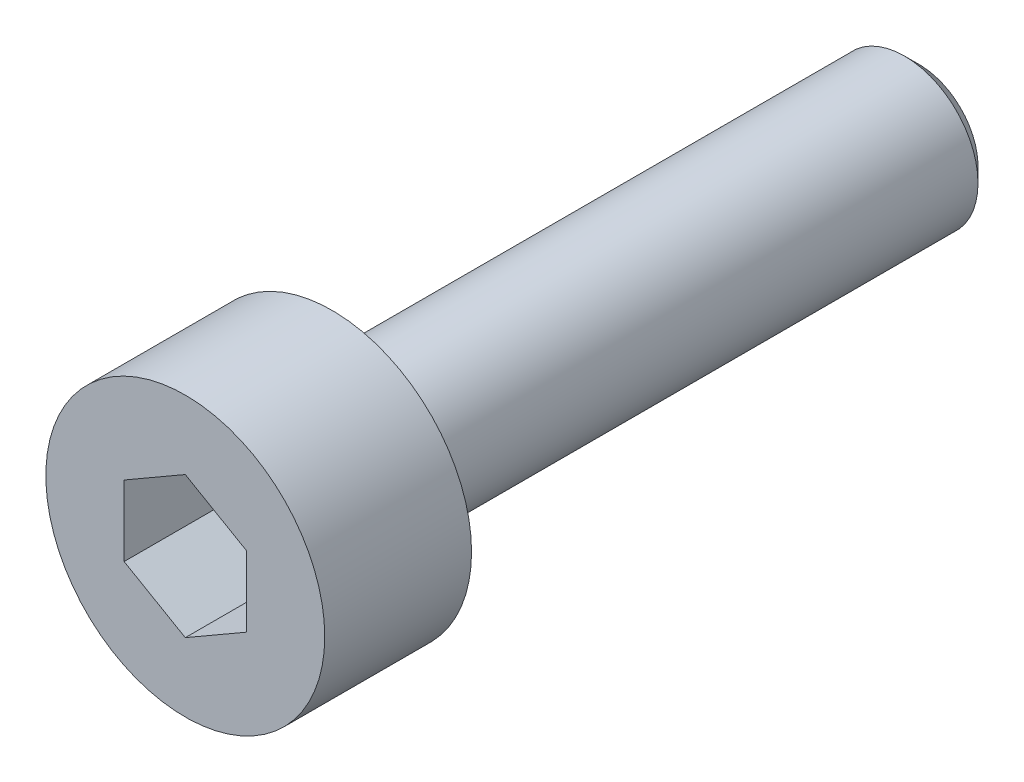
from build123d import *

# Parameters (mm, degrees)
SKETCH1_R           = 2.85
BOSS_EXTRUDE1_DEPTH = 3
SKETCH2_R           = 1.5
BOSS_EXTRUDE2_DEPTH = 12
CHAMFER1_SIZE       = 0.3
CUT_EXTRUDE1_DEPTH  = 2


with BuildPart() as part:
    # Sketch1 → Boss-Extrude1 (new body)
    with BuildSketch(Plane.XY):
        Circle(SKETCH1_R)
    extrude(amount=BOSS_EXTRUDE1_DEPTH)

    # Sketch2 → Boss-Extrude2 (add)
    with BuildSketch(Plane(origin=(0, 0, 0), x_dir=(-1, 0, 0), z_dir=(0, 0, -1))):
        Circle(SKETCH2_R)
    extrude(amount=BOSS_EXTRUDE2_DEPTH)

    # Chamfer1
    chamfer1_edges = [part.edges().sort_by_distance(p)[0] for p in [
        (1.5, 0, -12),
    ]]
    chamfer(chamfer1_edges, length=CHAMFER1_SIZE)

    # Sketch3 → Cut-Extrude1 (cut)
    with BuildSketch(Plane.XY.offset(3)):
        Polygon((0, 1.443375673), (-1.25, 0.721687836), (-1.25, -0.721687836), (0, -1.443375673), (1.25, -0.721687836), (1.25, 0.721687836), align=None)
    extrude(amount=-CUT_EXTRUDE1_DEPTH, mode=Mode.SUBTRACT)


solid = part.part
